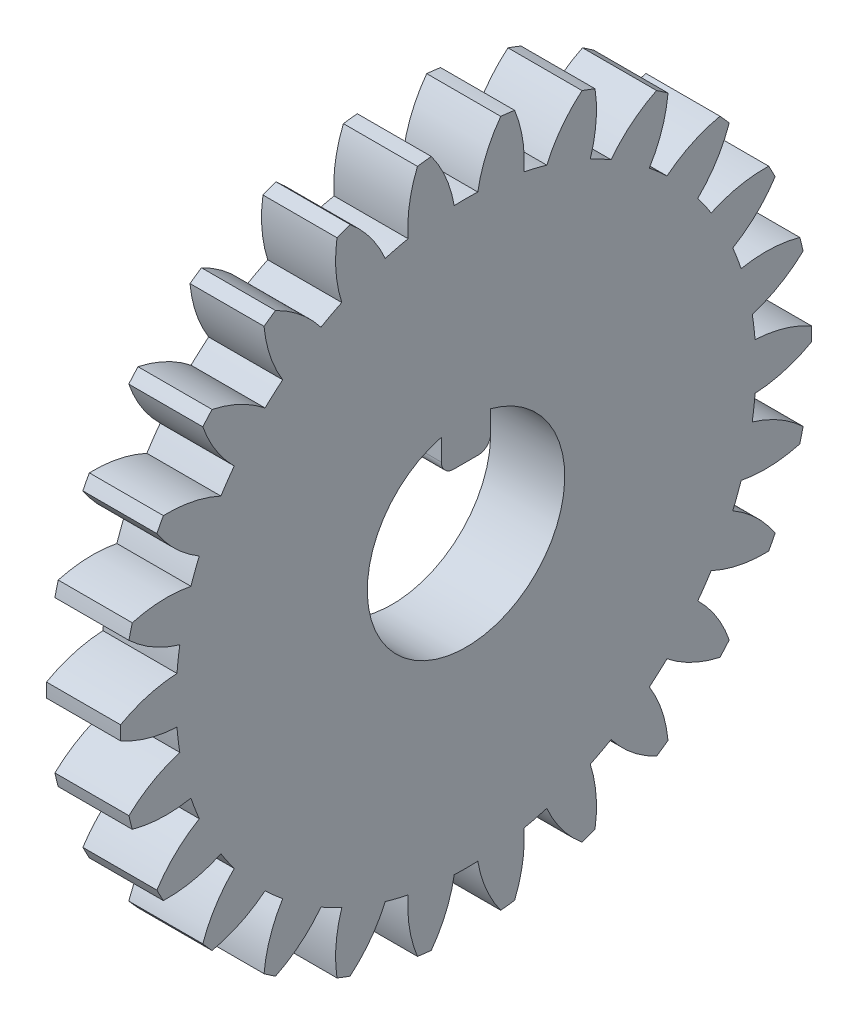
from build123d import *

# Parameters (mm, degrees)
BASPROSKE_W                 = 3
BASPROSKE_H                 = 14
TOOTHCUT_DEPTH              = 21.024984395
TEETHCUTS_COUNT             = 26
TEETHCUTS_ANGLE             = 346.153846154
BORSKE_R                    = 4
BORE_DEPTH                  = 50.0000508
DODANIE_WYCI_GNI_CIE1_DEPTH = 3


with BuildPart() as part:
    # BasProSke → Base-Revolve (revolve)
    with BuildSketch(Plane(origin=(0, 0, 0), x_dir=(1, 0, 0), z_dir=(0, 1, 0)), mode=Mode.PRIVATE) as base_revolve_sk:
        with Locations((1.5, 7)):
            Rectangle(BASPROSKE_W, BASPROSKE_H)
    revolve(base_revolve_sk.sketch.rotate(Axis((-10, 0, 0), (1, 0, 0)), 180), axis=Axis((-10, 0, 0), (1, 0, 0)))

    # TooCutSke → ToothCut (cut, through all)
    with BuildSketch(Plane(origin=(0, 0, 0), x_dir=(0, 0, -1), z_dir=(1, 0, 0))):
        with BuildLine():
            ThreePointArc((0.476965065, 11.739314517), (0, 11.749), (-0.476965065, 11.739314517))
            ThreePointArc((-0.476965065, 11.739314517), (-0.82065865, 12.901686978), (-1.424117301, 13.952911348))
            ThreePointArc((-1.424117301, 13.952911348), (0, 14.0254), (1.424117301, 13.952911348))
            ThreePointArc((1.424117301, 13.952911348), (0.82065865, 12.901686978), (0.476965065, 11.739314517))
        make_face()
    toothcut = extrude(amount=TOOTHCUT_DEPTH, mode=Mode.SUBTRACT)

    # TeethCuts: ToothCut ×26 about axis
    teethcuts_axis = Axis((-10, 0, 0), (1, 0, 0))
    for i in range(1, TEETHCUTS_COUNT):
        add(toothcut.rotate(teethcuts_axis, i * TEETHCUTS_ANGLE / (TEETHCUTS_COUNT - 1)), mode=Mode.SUBTRACT)

    # BorSke → Bore (cut, symmetric)
    with BuildSketch(Plane(origin=(0, 0, 0), x_dir=(0, 0, -1), z_dir=(1, 0, 0))):
        with Locations(Location((0, 0, 0), (0, 0, 180))):
            Circle(BORSKE_R)
    extrude(amount=BORE_DEPTH, both=True, mode=Mode.SUBTRACT)

    # Szkic1 → Dodanie-wyciągnięcie1 (add)
    with BuildSketch(Plane(origin=(3, 0, 0), x_dir=(0, 0, -1), z_dir=(1, 0, 0))):
        with BuildLine():
            Line((0, 4), (-1, 4))
            Line((-1, 4), (-1, 3))
            ThreePointArc((-1, 3), (-0.853553391, 2.646446609), (-0.5, 2.5))
            Line((-0.5, 2.5), (0.5, 2.5))
            ThreePointArc((0.5, 2.5), (0.853553391, 2.646446609), (1, 3))
            Line((1, 3), (1, 4))
            Line((1, 4), (0, 4))
        make_face()
    extrude(amount=-DODANIE_WYCI_GNI_CIE1_DEPTH)


solid = part.part
